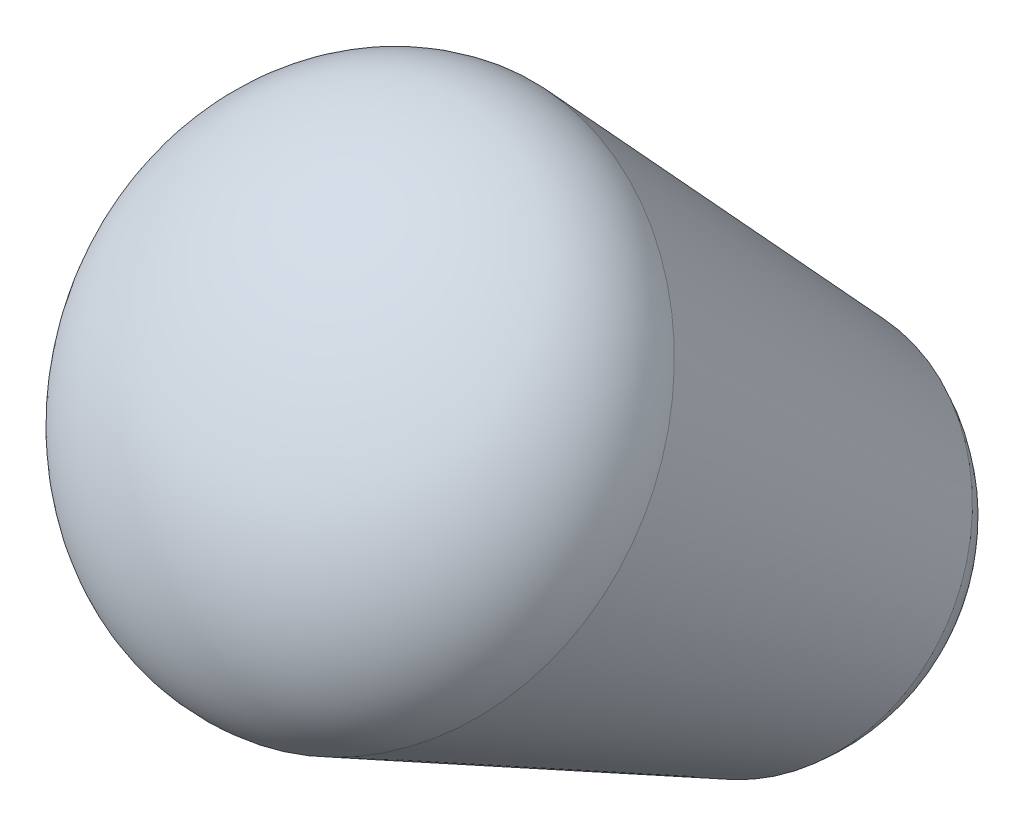
from build123d import *

# Parameters (mm, degrees)
SKETCH1_R           = 15
BOSS_EXTRUDE1_DEPTH = 29.373871
BOSS_EXTRUDE1_DRAFT = -9
DOME1_FACE_RADIUS   = 15
DOME1_HEIGHT        = 10
DOME2_FACE_RADIUS   = 10.347635881
DOME2_HEIGHT        = 7


with BuildPart() as part:
    # Sketch1 → Boss-Extrude1 (with draft: the straight prism first)
    with BuildSketch(Plane(origin=(0, -51.695936183, -126.441346307), x_dir=(1, 0, 0), z_dir=(0, 0.6212491278761147, 0.7836131195386961))):
        Circle(SKETCH1_R)
    extrude(amount=-BOSS_EXTRUDE1_DEPTH)
    # Boss-Extrude1: the draft: its side faces are tilted about the plane it starts from
    boss_extrude1_sides = [part.faces().sort_by_distance(p)[0] for p in [
        (-15, -60.820182053, -137.950221651),
    ]]
    draft(boss_extrude1_sides, Plane(origin=(0, -51.695936183, -126.441346307), x_dir=(1, 0, 0), z_dir=(0, 0.6212491278761147, 0.7836131195386961)), BOSS_EXTRUDE1_DRAFT)

    # Dome1: an elliptical dome of height H over a round flat face of radius A is half a spheroid: the quarter ellipse of half axes A and H revolved about the face's axis
    with BuildSketch(Plane((0, -51.695936183, -126.441346307), x_dir=(0, 0.7836131195388694, -0.6212491278758964), z_dir=(1, 0, 0)), mode=Mode.PRIVATE) as dome1_quarter:
        Ellipse(DOME1_FACE_RADIUS, DOME1_HEIGHT)
        Rectangle(DOME1_FACE_RADIUS, DOME1_HEIGHT, align=(Align.MIN, Align.MIN), mode=Mode.INTERSECT)
    revolve(dome1_quarter.sketch, axis=Axis((0, -51.695936183, -126.441346307), (0, 0.621249127876, 0.783613119539)))

    # Dome2: a dome of height H over a round flat face of radius A is a cap of a sphere of radius (A * A + H * H) / (2 * H)
    dome2_r = (DOME2_FACE_RADIUS * DOME2_FACE_RADIUS + DOME2_HEIGHT * DOME2_HEIGHT) / (2 * DOME2_HEIGHT)
    dome2_base = Plane((0, -69.944427924, -149.459096995), z_dir=(0, -0.621249127876, -0.783613119539))
    with Locations(dome2_base.offset(DOME2_HEIGHT - dome2_r)):
        dome2_ball = Sphere(dome2_r, mode=Mode.PRIVATE)
    add(split(dome2_ball, bisect_by=dome2_base, keep=Keep.TOP, mode=Mode.PRIVATE))


solid = part.part
